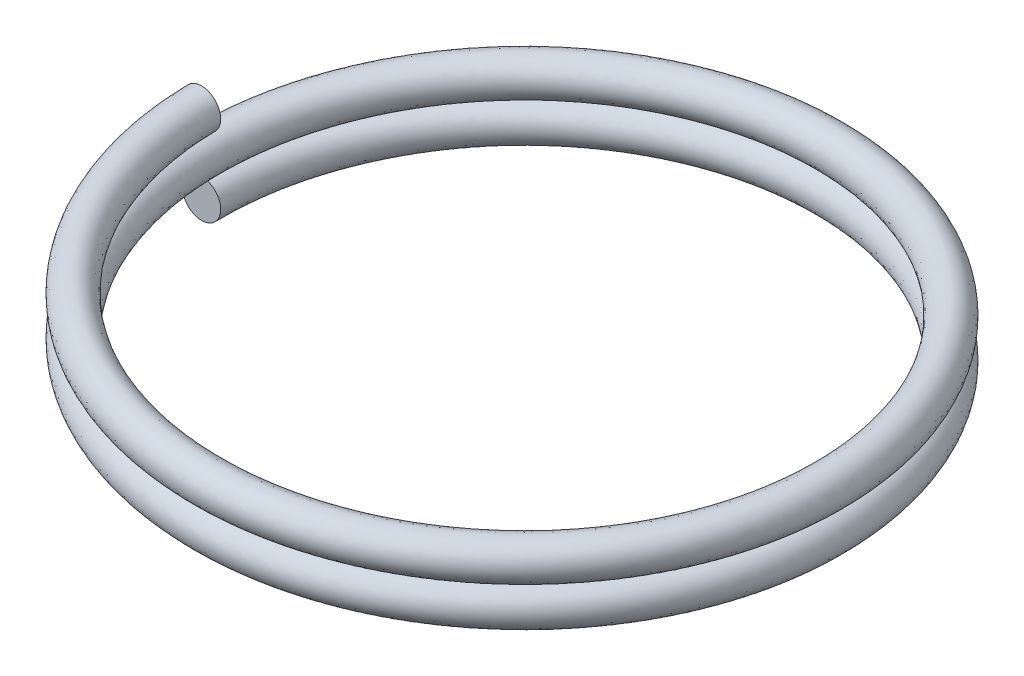
from build123d import *

# Parameters (mm, degrees)
SWEEP3_PITCH       = 0.5207
SWEEP3_HEIGHT      = 1.0414
SWEEP3_RADIUS      = 4.1275
SWEEP3_START_ANGLE = -90
SKETCH2_R          = 0.254


with BuildPart() as part:
    # Sweep3: sweep along a helix
    with BuildLine() as sweep3_path:
        add(Helix(SWEEP3_PITCH, SWEEP3_HEIGHT, SWEEP3_RADIUS, center=(0, 0, 0), direction=(0, 1, 0), lefthand=True, mode=Mode.PRIVATE).rotate(Axis((0, 0, 0), (0, 1, 0)), SWEEP3_START_ANGLE))
    # Sketch2 → Sweep3 (sweep)
    with BuildSketch(Plane.XY):
        with Locations((-4.1275, 0)):
            Circle(SKETCH2_R)
    sweep(path=sweep3_path.line, is_frenet=True)


solid = part.part
